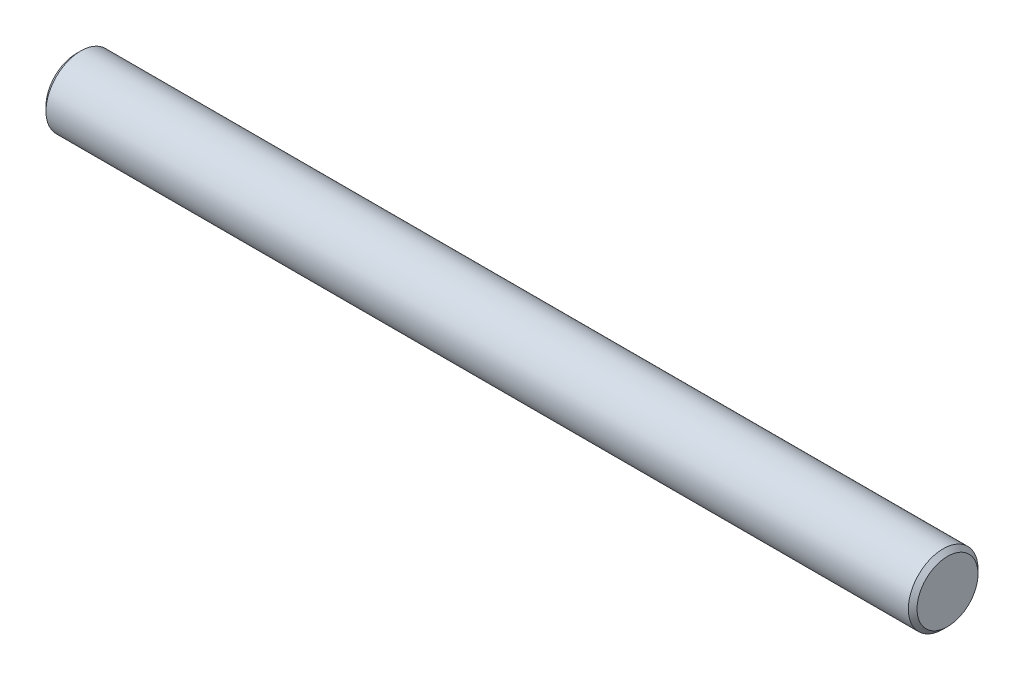
from build123d import *

# Parameters (mm, degrees)
SKETCH1_R           = 4
BOSS_EXTRUDE1_DEPTH = 50
CHAMFER1_SIZE       = 0.5


with BuildPart() as part:
    # Sketch1 → Boss-Extrude1 (new body, symmetric)
    with BuildSketch(Plane(origin=(0, 0, 0), x_dir=(0, -1, 0), z_dir=(1, 0, 0))):
        Circle(SKETCH1_R)
    extrude(amount=BOSS_EXTRUDE1_DEPTH, both=True)

    # Chamfer1
    chamfer1_edges = [part.edges().sort_by_distance(p)[0] for p in [
        (-50, 4, 0),
        (50, 4, 0),
    ]]
    chamfer(chamfer1_edges, length=CHAMFER1_SIZE)


solid = part.part
